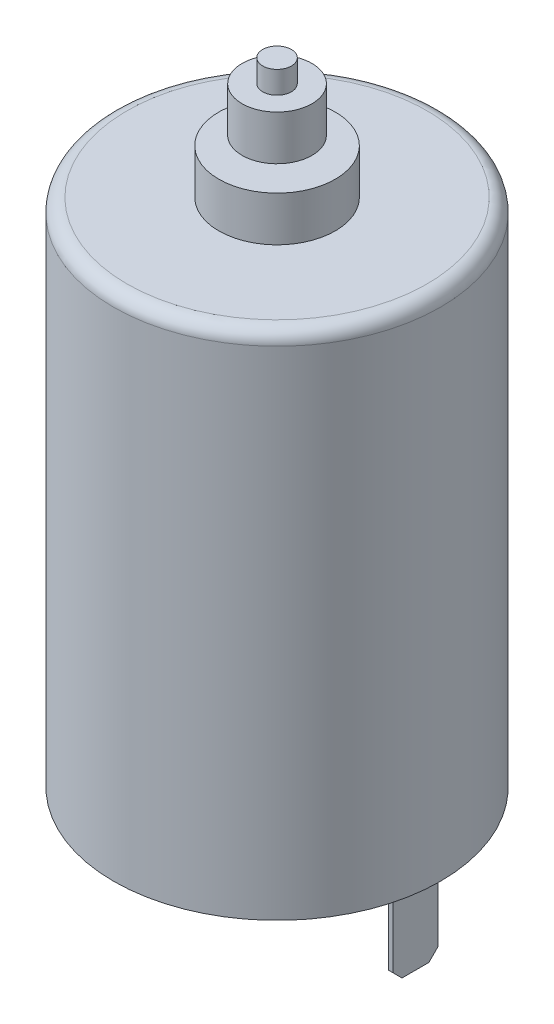
from build123d import *

# Parameters (mm, degrees)
SKETCH1_R           = 18.25
BOSS_EXTRUDE1_DEPTH = 57
SKETCH2_R           = 6.5
BOSS_EXTRUDE2_DEPTH = 5
FILLET1_R           = 1.5
SKETCH3_R           = 1.6
BOSS_EXTRUDE3_DEPTH = 8.5
BOSS_EXTRUDE4_START = -2.5
SKETCH4_R           = 3.9
BOSS_EXTRUDE4_DEPTH = 5
SKETCH5_R           = 5
BOSS_EXTRUDE5_DEPTH = 3
SKETCH6_R           = 1.5
BOSS_EXTRUDE6_DEPTH = 2
SKETCH7_W           = 0.5
SKETCH7_H           = 5
BOSS_EXTRUDE7_DEPTH = 10
CHAMFER1_SIZE       = 1


with BuildPart() as part:
    # Sketch1 → Boss-Extrude1 (new body)
    with BuildSketch(Plane(origin=(0, 0, 0), x_dir=(1, 0, 0), z_dir=(0, 1, 0))):
        Circle(SKETCH1_R)
    extrude(amount=BOSS_EXTRUDE1_DEPTH)

    # Sketch2 → Boss-Extrude2 (add)
    with BuildSketch(Plane(origin=(0, 57, 0), x_dir=(1, 0, 0), z_dir=(0, 1, 0))):
        Circle(SKETCH2_R)
    extrude(amount=BOSS_EXTRUDE2_DEPTH)

    # Fillet1
    fillet1_edges = [part.edges().sort_by_distance(p)[0] for p in [
        (-18.25, 57, 0),
    ]]
    fillet(fillet1_edges, radius=FILLET1_R)

    # Sketch3 → Boss-Extrude3 (add)
    with BuildSketch(Plane(origin=(0, 62, 0), x_dir=(1, 0, 0), z_dir=(0, 1, 0))):
        Circle(SKETCH3_R)
    extrude(amount=BOSS_EXTRUDE3_DEPTH)

    # Sketch4 → Boss-Extrude4 (add)
    with BuildSketch(Plane(origin=(0, 70.5, 0), x_dir=(1, 0, 0), z_dir=(0, 1, 0)).offset(BOSS_EXTRUDE4_START)):
        Circle(SKETCH4_R)
    extrude(amount=-BOSS_EXTRUDE4_DEPTH)

    # Sketch5 → Boss-Extrude5 (add)
    with BuildSketch(Plane.XZ):
        Circle(SKETCH5_R)
    extrude(amount=BOSS_EXTRUDE5_DEPTH)

    # Sketch6 → Boss-Extrude6 (add)
    with BuildSketch(Plane.XZ.offset(3)):
        Circle(SKETCH6_R)
    extrude(amount=BOSS_EXTRUDE6_DEPTH)

    # Sketch7 → Boss-Extrude7 (add)
    with BuildSketch(Plane.XZ):
        with Locations((15.2, 0)):
            Rectangle(SKETCH7_W, SKETCH7_H)
        with Locations((-15.2, 0)):
            Rectangle(SKETCH7_W, SKETCH7_H)
    extrude(amount=BOSS_EXTRUDE7_DEPTH)

    # Chamfer1
    chamfer1_edges = [part.edges().sort_by_distance(p)[0] for p in [
        (15.2, -10, -2.5),
        (15.2, -10, 2.5),
        (-15.2, -10, -2.5),
        (-15.2, -10, 2.5),
    ]]
    chamfer(chamfer1_edges, length=CHAMFER1_SIZE)


solid = part.part
